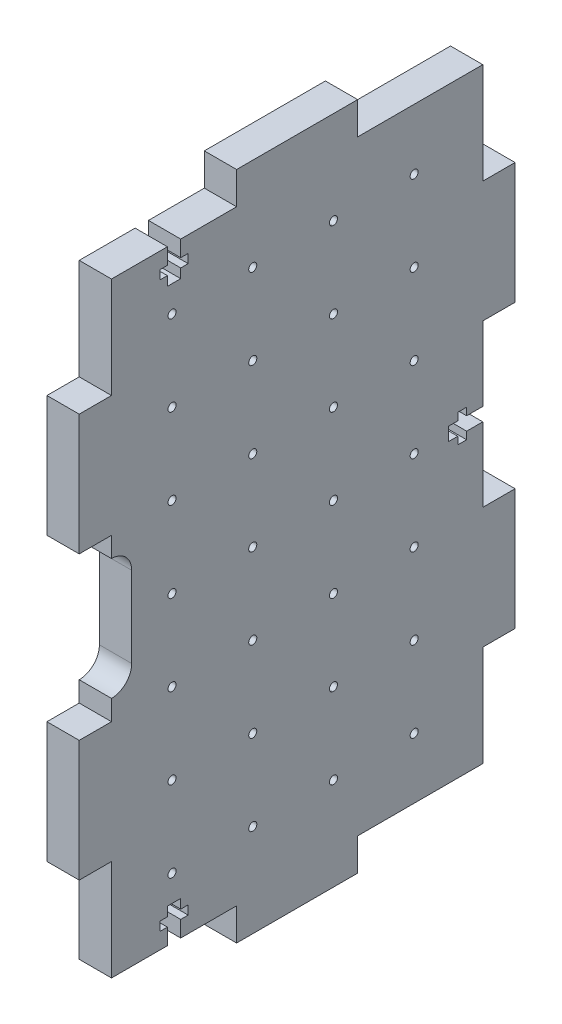
from build123d import *

# Parameters (mm, degrees)
SKETCH1_W           = 92
SKETCH1_H           = 150
BOSS_EXTRUDE1_DEPTH = 8
SKETCH2_W           = 30
SKETCH2_H           = 8
SKETCH2_W_2         = 8
SKETCH2_H_2         = 30
BOSS_EXTRUDE2_DEPTH = 8
SKETCH3_R           = 1
CUT_EXTRUDE1_DEPTH  = 8
CUT_EXTRUDE2_DEPTH  = 9
CUT_EXTRUDE4_DEPTH  = 9


with BuildPart() as part:
    # Sketch1 → Boss-Extrude1 (new body)
    with BuildSketch(Plane(origin=(0, 0, 0), x_dir=(0, 0, -1), z_dir=(1, 0, 0))):
        with Locations((46, 75)):
            Rectangle(SKETCH1_W, SKETCH1_H)
    extrude(amount=BOSS_EXTRUDE1_DEPTH)

    # Sketch2 → Boss-Extrude2 (add)
    with BuildSketch(Plane.ZY):
        with Locations((-46, 154)):
            Rectangle(SKETCH2_W, SKETCH2_H)
        with Locations((-46, -4)):
            Rectangle(SKETCH2_W, SKETCH2_H)
        with Locations((4, 40)):
            Rectangle(SKETCH2_W_2, SKETCH2_H_2)
        with Locations((4, 110)):
            Rectangle(SKETCH2_W_2, SKETCH2_H_2)
        with Locations((-96, 40)):
            Rectangle(SKETCH2_W_2, SKETCH2_H_2)
        with Locations((-96, 110)):
            Rectangle(SKETCH2_W_2, SKETCH2_H_2)
    extrude(amount=-BOSS_EXTRUDE2_DEPTH)

    # Sketch3 → Cut-Extrude1 (cut)
    with BuildSketch(Plane(origin=(8, 0, 0), x_dir=(0, 0, -1), z_dir=(1, 0, 0))):
        with Locations((15, 135)):
            Circle(SKETCH3_R)
        with Locations((35, 135)):
            Circle(SKETCH3_R)
        with Locations((55, 135)):
            Circle(SKETCH3_R)
        with Locations((75, 135)):
            Circle(SKETCH3_R)
        with Locations((15, 115)):
            Circle(SKETCH3_R)
        with Locations((35, 115)):
            Circle(SKETCH3_R)
        with Locations((55, 115)):
            Circle(SKETCH3_R)
        with Locations((75, 115)):
            Circle(SKETCH3_R)
        with Locations((15, 95)):
            Circle(SKETCH3_R)
        with Locations((35, 95)):
            Circle(SKETCH3_R)
        with Locations((55, 95)):
            Circle(SKETCH3_R)
        with Locations((75, 95)):
            Circle(SKETCH3_R)
        with Locations((15, 75)):
            Circle(SKETCH3_R)
        with Locations((35, 75)):
            Circle(SKETCH3_R)
        with Locations((55, 75)):
            Circle(SKETCH3_R)
        with Locations((75, 75)):
            Circle(SKETCH3_R)
        with Locations((15, 55)):
            Circle(SKETCH3_R)
        with Locations((35, 55)):
            Circle(SKETCH3_R)
        with Locations((55, 55)):
            Circle(SKETCH3_R)
        with Locations((75, 55)):
            Circle(SKETCH3_R)
        with Locations((15, 35)):
            Circle(SKETCH3_R)
        with Locations((35, 35)):
            Circle(SKETCH3_R)
        with Locations((55, 35)):
            Circle(SKETCH3_R)
        with Locations((75, 35)):
            Circle(SKETCH3_R)
        with Locations((15, 15)):
            Circle(SKETCH3_R)
        with Locations((35, 15)):
            Circle(SKETCH3_R)
        with Locations((55, 15)):
            Circle(SKETCH3_R)
        with Locations((75, 15)):
            Circle(SKETCH3_R)
    extrude(amount=-CUT_EXTRUDE1_DEPTH, mode=Mode.SUBTRACT)

    # Sketch4 → Cut-Extrude2 (cut, through all)
    with BuildSketch(Plane(origin=(8, 0, 0), x_dir=(0, 0, -1), z_dir=(1, 0, 0))):
        with BuildLine():
            Line((5, 85), (5, 65))
            ThreePointArc((5, 65), (0, 60), (-5, 65))
            Line((-5, 65), (-5, 85))
            ThreePointArc((-5, 85), (0, 90), (5, 85))
        make_face()
    extrude(amount=-CUT_EXTRUDE2_DEPTH, mode=Mode.SUBTRACT)

    # Sketch5 → Cut-Extrude4 (cut, through all)
    with BuildSketch(Plane(origin=(8, 0, 0), x_dir=(0, 0, -1), z_dir=(1, 0, 0))):
        Polygon((92, 76.65), (88, 76.65), (88, 78.5), (85.8, 78.5), (85.8, 76.65), (83.5, 76.65), (83.5, 73.35), (85.8, 73.35), (85.8, 71.5), (88, 71.5), (88, 73.35), (92, 73.35), align=None)
        Polygon((17.15, 0), (17.15, 4), (19, 4), (19, 6.2), (17.15, 6.2), (17.15, 8.5), (13.85, 8.5), (13.85, 6.2), (12, 6.2), (12, 4), (13.85, 4), (13.85, 0), align=None)
        Polygon((13.85, 150), (17.15, 150), (17.15, 146), (19, 146), (19, 143.8), (17.15, 143.8), (17.15, 141.5), (13.85, 141.5), (13.85, 143.8), (12, 143.8), (12, 146), (13.85, 146), align=None)
    extrude(amount=-CUT_EXTRUDE4_DEPTH, mode=Mode.SUBTRACT)


solid = part.part
